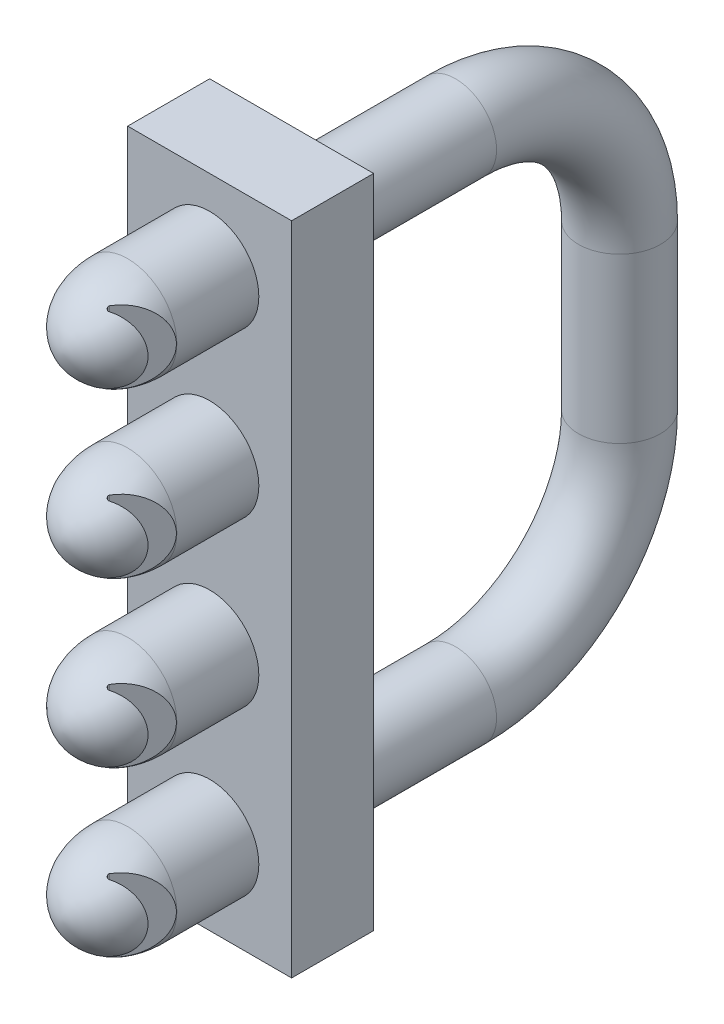
from build123d import *

# Parameters (mm, degrees)
SKETCH1_W               = 10
SKETCH1_H               = 40
BOSS_EXTRUDE1_DEPTH     = 5
SKETCH2_R               = 2.501304298
SKETCH5_R               = 3
BOSS_EXTRUDE2_DEPTH     = 5
LPATTERN2_COUNT         = 4
LPATTERN2_PITCH         = 10
LPATTERN5_COUNT         = 4
LPATTERN5_PITCH         = 10
CUT_EXTRUDE2_DEPTH      = 33
CUT_EXTRUDE2_DEPTH_BACK = 9
FILLET4_R               = 0.1


with BuildPart() as part:
    # Sketch1 → Boss-Extrude1 (new body)
    with BuildSketch(Plane.XY):
        Rectangle(SKETCH1_W, SKETCH1_H)
    extrude(amount=BOSS_EXTRUDE1_DEPTH)

    # Sweep1: sweep along a path in Sketch3
    with BuildLine(Plane(origin=(0, 0, 0), x_dir=(0, 0, -1), z_dir=(1, 0, 0))) as sweep1_path:
        Line((0, 15), (10, 15))
        ThreePointArc((10, 15), (17.071067812, 12.071067812), (20, 5))
        Line((20, 5), (20, -5))
        ThreePointArc((20, -5), (17.071067812, -12.071067812), (10, -15))
        Line((10, -15), (0, -15))
    # Sketch2 → Sweep1 (sweep)
    with BuildSketch(Plane(origin=(0, 0, 0), x_dir=(-1, 0, 0), z_dir=(0, 0, -1))):
        with Locations((0, 15)):
            Circle(SKETCH2_R)
    sweep(path=sweep1_path.line)

    # Sketch5 → Boss-Extrude2 (add)
    with BuildSketch(Plane.XY.offset(5)):
        with Locations((0, 15)):
            Circle(SKETCH5_R)
    boss_extrude2 = extrude(amount=BOSS_EXTRUDE2_DEPTH)

    # Sketch9 → Revolve2 (revolve)
    with BuildSketch(Plane(origin=(0, 0, 0), x_dir=(0, 0, -1), z_dir=(1, 0, 0))):
        with BuildLine():
            Line((-10, 15), (-14, 15))
            add(Edge.make_bspline(
                [(-10, 18), (-13.224740058, 17.941244514), (-14.000011991, 15.685721652), (-14, 15)],
                knots=[0, 0, 0, 0, 1, 1, 1, 1], degree=3))
            Line((-10, 18), (-10, 15))
        make_face()
    revolve2 = revolve(axis=Axis((0, 15, 10), (0, 0, 1)))

    # LPattern2: Boss-Extrude2 ×4
    with Locations(*[(0, -i * LPATTERN2_PITCH, 0) for i in range(1, LPATTERN2_COUNT)]):
        add(boss_extrude2)

    # LPattern5: Revolve2 ×4
    with Locations(*[(0, -i * LPATTERN5_PITCH, 0) for i in range(1, LPATTERN5_COUNT)]):
        add(revolve2)

    # Sketch12 → Cut-Extrude2 (cut, two sides)
    with BuildSketch(Plane(origin=(0, 12, 0), x_dir=(-1, 0, 0), z_dir=(0, -1, 0))) as cut_extrude2_sk:
        Polygon((-0.766044443, -12.68721239), (-4.506475593, -10.527673459), (-3.542294178, -9.378606794), align=None)
    extrude(amount=CUT_EXTRUDE2_DEPTH, mode=Mode.SUBTRACT)
    extrude(cut_extrude2_sk.sketch, amount=-CUT_EXTRUDE2_DEPTH_BACK, mode=Mode.SUBTRACT)

    # Fillet4
    fillet4_edges = [part.edges().sort_by_distance(p)[0] for p in [
        (0.766044443, 15, 12.68721239),
        (0.766044443, 5, 12.68721239),
        (0.766044443, -5, 12.68721239),
        (0.766044443, -15, 12.68721239),
    ]]
    fillet(fillet4_edges, radius=FILLET4_R)


solid = part.part
